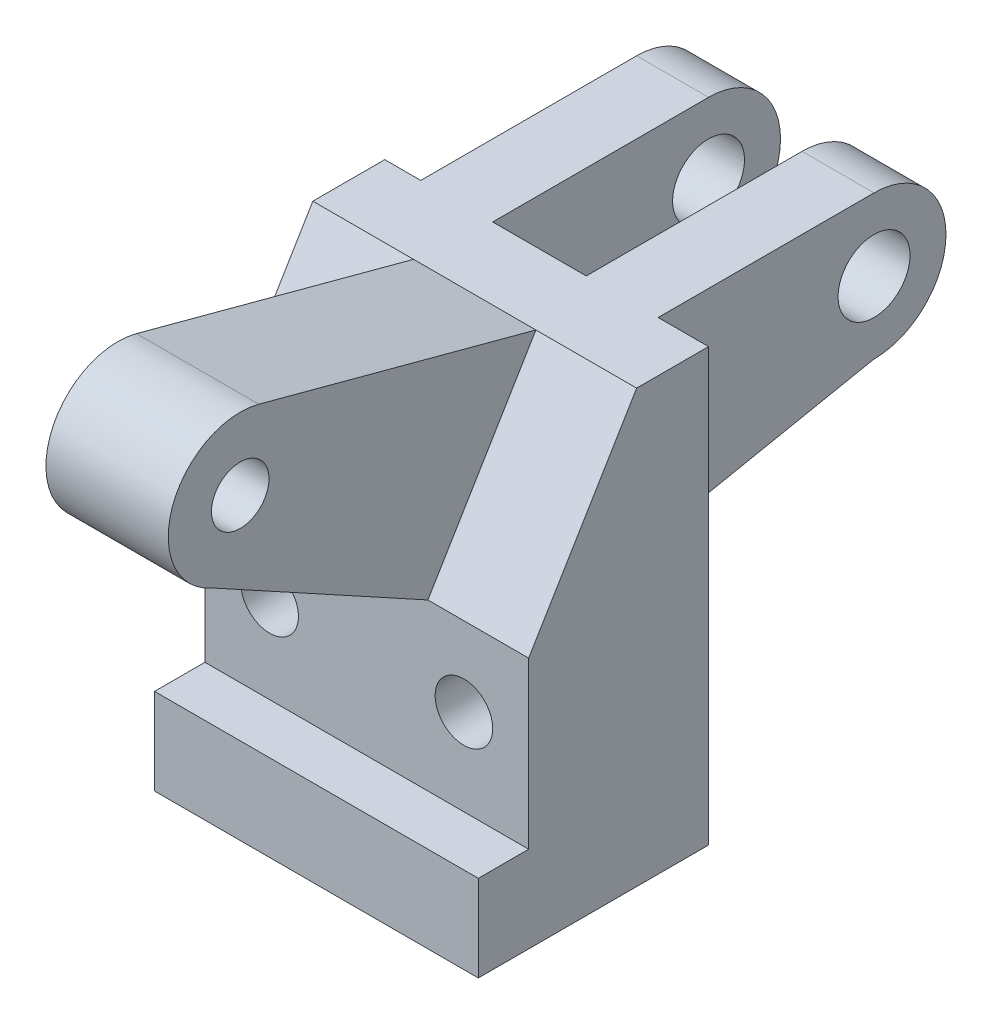
from build123d import *

# Parameters (mm, degrees)
SKETCH1_W                 = 1143
SKETCH1_H                 = 635
BOSS_EXTRUDE1_DEPTH       = 584.2
SKETCH2_W                 = 1143
SKETCH2_H                 = 177.8
BOSS_EXTRUDE2_DEPTH       = 304.8
SKETCH4_W                 = 1143
SKETCH4_H                 = 635
BOSS_EXTRUDE3_DEPTH       = 304.8
SKETCH5_W                 = 254
SKETCH5_H                 = 1524
BOSS_EXTRUDE4_DEPTH       = 1143
BOSS_EXTRUDE5_DEPTH       = 1143
SKETCH8_W                 = 254
SKETCH8_H                 = 762
BOSS_EXTRUDE6_DEPTH       = 660.4
BOSS_EXTRUDE7_DEPTH       = 254
SKETCH10_R                = 127
CUT_EXTRUDE2_DEPTH        = 254
CUT_EXTRUDE3_DEPTH        = 254
SKETCH12_W                = 254
SKETCH12_H                = 762
BOSS_EXTRUDE8_DEPTH       = 660.4
SKETCH13_R                = 254
SKETCH13_R_2              = 127
BOSS_EXTRUDE9_DEPTH       = 254
SKETCH14_R                = 127
CUT_EXTRUDE4_DEPTH        = 254
SKETCH15_R                = 101.6
CUT_EXTRUDE5_DEPTH        = 1652
SKETCH16_R                = 101.6
BOSS_EXTRUDE10_DEPTH      = 215.9
BOSS_EXTRUDE10_DEPTH_BACK = 215.9


with BuildPart() as part:
    # Sketch1 → Boss-Extrude1 (new body)
    with BuildSketch(Plane(origin=(0, 0, 0), x_dir=(1, 0, 0), z_dir=(0, 1, 0))):
        with Locations((571.5, -317.5)):
            Rectangle(SKETCH1_W, SKETCH1_H)
    extrude(amount=BOSS_EXTRUDE1_DEPTH)

    # Sketch2 → Boss-Extrude2 (add)
    with BuildSketch(Plane.XZ):
        with Locations((571.5, 723.9)):
            Rectangle(SKETCH2_W, SKETCH2_H)
    extrude(amount=-BOSS_EXTRUDE2_DEPTH)

    # Sketch4 → Boss-Extrude3 (add)
    with BuildSketch(Plane(origin=(0, 584.2, 0), x_dir=(1, 0, 0), z_dir=(0, 1, 0))):
        with Locations((571.5, -317.5)):
            Rectangle(SKETCH4_W, SKETCH4_H)
    extrude(amount=BOSS_EXTRUDE3_DEPTH)

    # Sketch5 → Boss-Extrude4 (add)
    with BuildSketch(Plane.ZY):
        with Locations((127, 762)):
            Rectangle(SKETCH5_W, SKETCH5_H)
    extrude(amount=-BOSS_EXTRUDE4_DEPTH)

    # Sketch6 → Boss-Extrude5 (add)
    with BuildSketch(Plane.ZY):
        Polygon((254, 1524), (635, 889), (254, 889), align=None)
    extrude(amount=-BOSS_EXTRUDE5_DEPTH)

    # Sketch8 → Boss-Extrude6 (add)
    with BuildSketch(Plane(origin=(0, 1524, 0), x_dir=(1, 0, 0), z_dir=(0, 1, 0))):
        with Locations((254, 381)):
            Rectangle(SKETCH8_W, SKETCH8_H)
    extrude(amount=-BOSS_EXTRUDE6_DEPTH)

    # Sketch9 → Boss-Extrude7 (add)
    with BuildSketch(Plane.ZY.offset(-127)):
        with BuildLine():
            ThreePointArc((-508, 1270), (-582.394877579, 1449.605122421), (-762, 1524))
            Line((-762, 1524), (-762, 1397))
            ThreePointArc((-762, 1397), (-672.197438789, 1359.802561211), (-635, 1270))
            ThreePointArc((-635, 1270), (-672.197438789, 1180.197438789), (-762, 1143))
            Line((-762, 1143), (-762, 1016))
            ThreePointArc((-762, 1016), (-582.394877579, 1090.394877579), (-508, 1270))
        make_face()
        with BuildLine():
            Line((-762, 1397), (-762, 1524))
            ThreePointArc((-762, 1524), (-1016, 1270), (-762, 1016))
            Line((-762, 1016), (-762, 1143))
            ThreePointArc((-762, 1143), (-889, 1270), (-762, 1397))
        make_face()
    extrude(amount=-BOSS_EXTRUDE7_DEPTH)

    # Sketch10 → Cut-Extrude2 (cut)
    with BuildSketch(Plane.ZY.offset(-127)):
        with Locations((-762, 1270)):
            Circle(SKETCH10_R)
    extrude(amount=-CUT_EXTRUDE2_DEPTH, mode=Mode.SUBTRACT)

    # Sketch11 → Cut-Extrude3 (cut)
    with BuildSketch(Plane.ZY.offset(-127)):
        Polygon((-762, 863.6), (0, 863.6), (-762, 1016), align=None)
    extrude(amount=-CUT_EXTRUDE3_DEPTH, mode=Mode.SUBTRACT)

    # Sketch12 → Boss-Extrude8 (add)
    with BuildSketch(Plane(origin=(0, 1524, 0), x_dir=(1, 0, 0), z_dir=(0, 1, 0))):
        with Locations((838.2, 381)):
            Rectangle(SKETCH12_W, SKETCH12_H)
    extrude(amount=-BOSS_EXTRUDE8_DEPTH)

    # Sketch13 → Boss-Extrude9 (add)
    with BuildSketch(Plane(origin=(965.2, 0, 0), x_dir=(0, 0, -1), z_dir=(1, 0, 0))):
        with Locations((762, 1270)):
            Circle(SKETCH13_R)
        with Locations((762, 1270)):
            Circle(SKETCH13_R_2, mode=Mode.SUBTRACT)
    extrude(amount=-BOSS_EXTRUDE9_DEPTH)

    # Sketch14 → Cut-Extrude4 (cut)
    with BuildSketch(Plane(origin=(965.2, 0, 0), x_dir=(0, 0, -1), z_dir=(1, 0, 0))):
        with Locations((762, 1270)):
            Circle(SKETCH14_R)
        Polygon((762, 1016), (0, 863.6), (762, 863.6), align=None)
    extrude(amount=-CUT_EXTRUDE4_DEPTH, mode=Mode.SUBTRACT)

    # Sketch15 → Cut-Extrude5 (cut, through all)
    with BuildSketch(Plane.XY.offset(635)):
        with Locations((914.4, 609.6)):
            Circle(SKETCH15_R)
        with Locations((228.6, 609.6)):
            Circle(SKETCH15_R)
    extrude(amount=-CUT_EXTRUDE5_DEPTH, mode=Mode.SUBTRACT)

    # Sketch16 → Boss-Extrude10 (add, two sides)
    with BuildSketch(Plane(origin=(571.5, 0, 0), x_dir=(0, 0, -1), z_dir=(1, 0, 0))) as boss_extrude10_sk:
        with BuildLine():
            Line((-635, 889), (-1397.931735388, 1307.238213289))
            ThreePointArc((-1397.931735388, 1307.238213289), (-1537.726937635, 1623.815968567), (-1232.007743802, 1785.988556358))
            Line((-1232.007743802, 1785.988556358), (-254, 1524))
            Line((-254, 1524), (-635, 889))
        make_face()
        with Locations((-1297.731905002, 1540.639143001)):
            Circle(SKETCH16_R, mode=Mode.SUBTRACT)
    extrude(amount=BOSS_EXTRUDE10_DEPTH)
    extrude(boss_extrude10_sk.sketch, amount=-BOSS_EXTRUDE10_DEPTH_BACK)


solid = part.part
